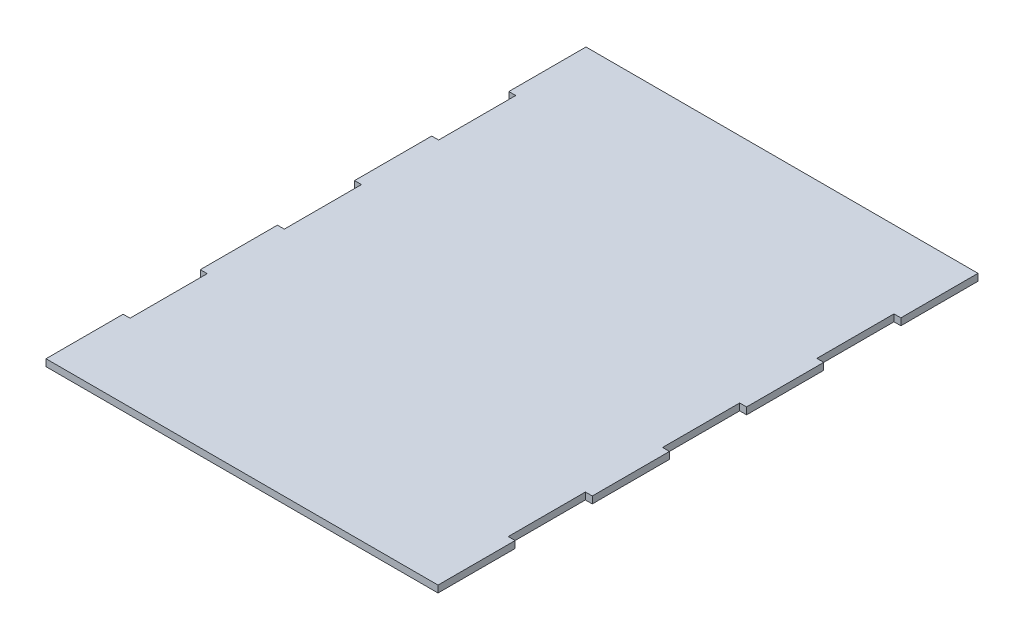
from build123d import *

# Parameters (mm, degrees)
BOSS_EXTRUDE1_DEPTH = 2.7


with BuildPart() as part:
    # Sketch1 → Boss-Extrude1 (new body)
    with BuildSketch(Plane(origin=(0, 0, 0), x_dir=(1, 0, 0), z_dir=(0, 1, 0))):
        Polygon((76.7, -105.6473627), (-76.7, -105.6473627), (-76.7, -75.462401929), (-74, -75.462401929), (-74, -45.277441157), (-76.7, -45.277441157), (-76.7, -15.092480386), (-74, -15.092480386), (-74, 15.092480386), (-76.7, 15.092480386), (-76.7, 45.277441157), (-74, 45.277441157), (-74, 75.462401929), (-76.7, 75.462401929), (-76.7, 105.6473627), (76.7, 105.6473627), (76.7, 75.462401929), (74, 75.462401929), (74, 45.277441157), (76.7, 45.277441157), (76.7, 15.092480386), (74, 15.092480386), (74, -15.092480386), (76.7, -15.092480386), (76.7, -45.277441157), (74, -45.277441157), (74, -75.462401929), (76.7, -75.462401929), align=None)
    extrude(amount=BOSS_EXTRUDE1_DEPTH)


solid = part.part
